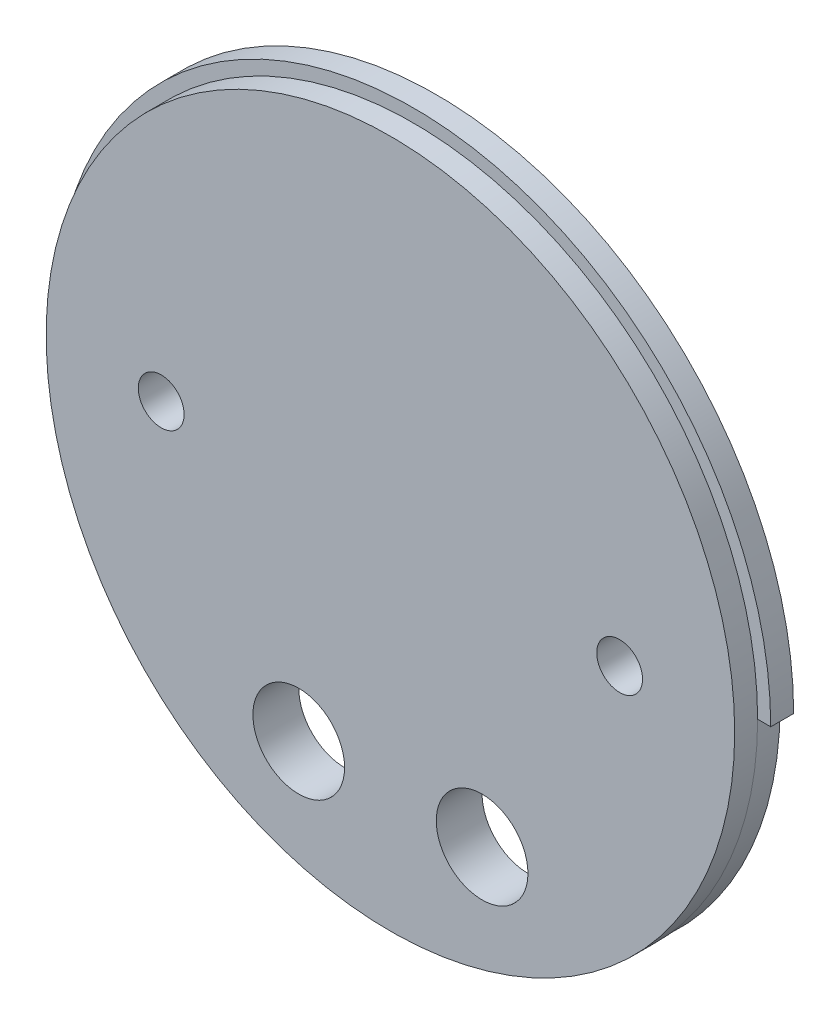
from build123d import *

# Parameters (mm, degrees)
SKETCH1_R           = 49.5046
BOSS_EXTRUDE1_DEPTH = 3.175
SKETCH2_R           = 47.6885
BOSS_EXTRUDE2_DEPTH = 3.175
SKETCH3_R           = 3.175
SKETCH3_R_2         = 6.35
CUT_EXTRUDE1_DEPTH  = 7.35
CUT_EXTRUDE2_DEPTH  = 4.175


with BuildPart() as part:
    # Sketch1 → Boss-Extrude1 (new body)
    with BuildSketch(Plane.XY):
        Circle(SKETCH1_R)
    extrude(amount=BOSS_EXTRUDE1_DEPTH)

    # Sketch2 → Boss-Extrude2 (add)
    with BuildSketch(Plane.XY.offset(3.175)):
        Circle(SKETCH2_R)
    extrude(amount=BOSS_EXTRUDE2_DEPTH)

    # Sketch3 → Cut-Extrude1 (cut, through all)
    with BuildSketch(Plane.XY.offset(6.35)):
        with Locations((-31.75, 0)):
            Circle(SKETCH3_R)
        with Locations((31.75, 0)):
            Circle(SKETCH3_R)
        with Locations((-12.7, -31.235352443)):
            Circle(SKETCH3_R_2)
        with Locations((12.7, -31.235352443)):
            Circle(SKETCH3_R_2)
    extrude(amount=-CUT_EXTRUDE1_DEPTH, mode=Mode.SUBTRACT)

    # Sketch4 → Cut-Extrude2 (cut, through all)
    with BuildSketch(Plane.XY.offset(3.175)):
        with BuildLine():
            Line((-50.165, 0), (-47.625, 0))
            ThreePointArc((-47.625, 0), (0, -47.625), (47.625, 0))
            Line((47.625, 0), (50.165, 0))
            ThreePointArc((50.165, 0), (0, -50.165), (-50.165, 0))
        make_face()
    extrude(amount=-CUT_EXTRUDE2_DEPTH, mode=Mode.SUBTRACT)


solid = part.part
